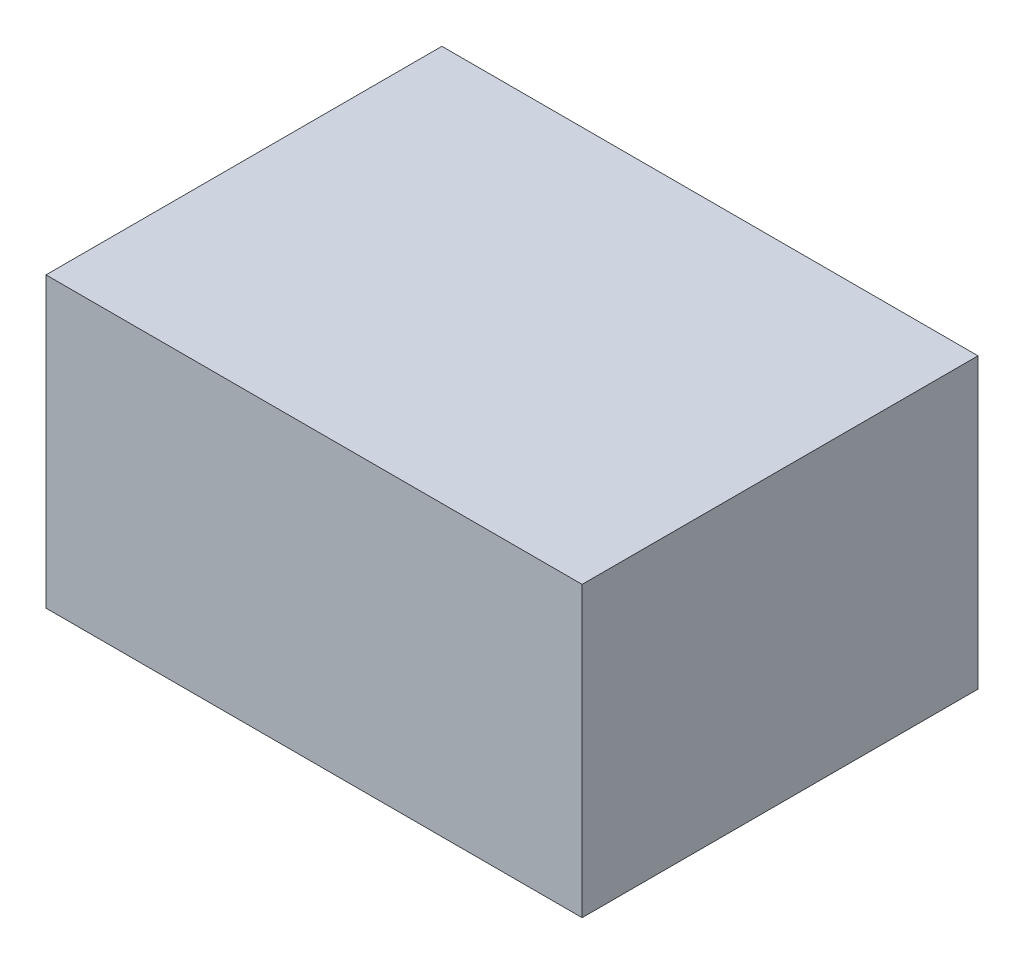
from build123d import *

# Parameters (mm, degrees)
SKIZZE1_W                       = 650
SKIZZE1_H                       = 350
AUFSATZ_LINEAR_AUSTRAGEN1_DEPTH = 480


with BuildPart() as part:
    # Skizze1 → Aufsatz-Linear austragen1 (new body)
    with BuildSketch(Plane.XY):
        Rectangle(SKIZZE1_W, SKIZZE1_H)
    extrude(amount=AUFSATZ_LINEAR_AUSTRAGEN1_DEPTH)


solid = part.part
